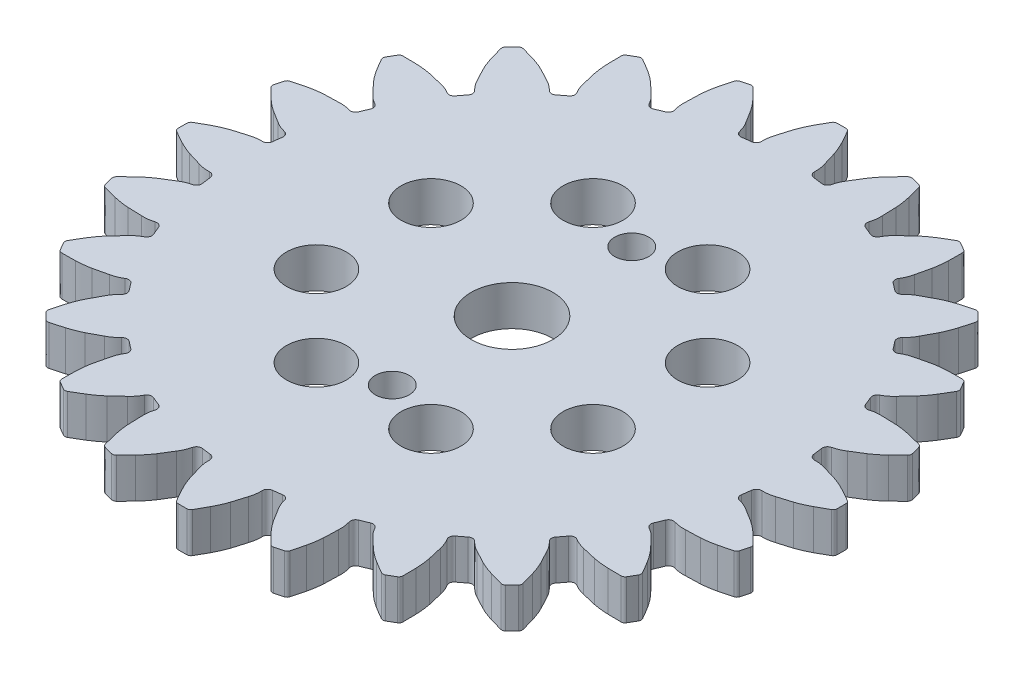
from build123d import *

# Parameters (mm, degrees)
BOSS_EXTRUDE1_DEPTH = 4
SKETCH2_R           = 4.1
CUT_EXTRUDE2_DEPTH  = 5
SKETCH3_R           = 1.7
CUT_EXTRUDE3_DEPTH  = 5
SKETCH4_R           = 3
CUT_EXTRUDE4_DEPTH  = 5


with BuildPart() as part:
    # Sketch1 → Boss-Extrude1 (new body)
    with BuildSketch(Plane(origin=(0, 0, 0), x_dir=(1, 0, 0), z_dir=(0, 1, 0))):
        with BuildLine():
            ThreePointArc((636.726842235, 307.914073759), (636.700055909, 308.139160781), (636.67140194, 308.364017679))
            ThreePointArc((636.67140194, 308.364017679), (636.640882301, 308.588628956), (636.608499097, 308.812979135))
            ThreePointArc((636.608499097, 308.812979135), (636.695878929, 309.191360962), (637.017496333, 309.409008123))
            ThreePointArc((637.017496333, 309.409008123), (637.592536167, 309.594733296), (638.123933391, 309.882451284))
            ThreePointArc((638.123933391, 309.882451284), (638.738760006, 310.263468262), (639.353529647, 310.644577163))
            ThreePointArc((639.353529647, 310.644577163), (639.964545893, 311.091711617), (640.534655463, 311.589953679))
            ThreePointArc((640.534655463, 311.589953679), (641.021585116, 312.059475229), (641.502718943, 312.534934179))
            ThreePointArc((641.502718943, 312.534934179), (641.605231633, 312.711177185), (641.607284789, 312.915055173))
            ThreePointArc((641.607284789, 312.915055173), (641.551805023, 313.130819634), (641.494870784, 313.346204869))
            ThreePointArc((641.494870784, 313.346204869), (641.436484664, 313.561201074), (641.376649319, 313.775798462))
            ThreePointArc((641.376649319, 313.775798462), (641.272932241, 313.9513354), (641.096032144, 314.052709976))
            ThreePointArc((641.096032144, 314.052709976), (640.441628552, 314.223902592), (639.785174328, 314.387055355))
            ThreePointArc((639.785174328, 314.387055355), (639.042323927, 314.533490853), (638.289601107, 314.615212526))
            ThreePointArc((638.289601107, 314.615212526), (637.566640531, 314.637877695), (636.843676574, 314.66043477))
            ThreePointArc((636.843676574, 314.66043477), (636.239614085, 314.643907245), (635.648752394, 314.517230045))
            ThreePointArc((635.648752394, 314.517230045), (635.261399971, 314.544909314), (634.996535903, 314.828907673))
            ThreePointArc((634.996535903, 314.828907673), (634.912405492, 315.039392229), (634.826530635, 315.249171121))
            ThreePointArc((634.826530635, 315.249171121), (634.738917252, 315.458229891), (634.649571379, 315.666554133))
            ThreePointArc((634.649571379, 315.666554133), (634.636041392, 316.054658476), (634.890368719, 316.3481302))
            ThreePointArc((634.890368719, 316.3481302), (635.397745334, 316.676358201), (635.836568741, 317.091808159))
            ThreePointArc((635.836568741, 317.091808159), (636.331831197, 317.618971136), (636.827014829, 318.146208157))
            ThreePointArc((636.827014829, 318.146208157), (637.301484289, 318.736249516), (637.723213312, 319.365069606))
            ThreePointArc((637.723213312, 319.365069606), (638.07203012, 319.944619264), (638.413711878, 320.528403941))
            ThreePointArc((638.413711878, 320.528403941), (638.467116486, 320.725173849), (638.416332176, 320.922636258))
            ThreePointArc((638.416332176, 320.922636258), (638.306898886, 321.116689504), (638.196158833, 321.31))
            ThreePointArc((638.196158833, 321.31), (638.084117059, 321.502558947), (637.970778664, 321.694357579))
            ThreePointArc((637.970778664, 321.694357579), (637.825163356, 321.837069287), (637.628053313, 321.889204493))
            ThreePointArc((637.628053313, 321.889204493), (636.951640073, 321.885191749), (636.275326942, 321.872882361))
            ThreePointArc((636.275326942, 321.872882361), (635.519888259, 321.822064359), (634.771662722, 321.706182432))
            ThreePointArc((634.771662722, 321.706182432), (634.067470253, 321.540959339), (633.363302494, 321.375630959))
            ThreePointArc((633.363302494, 321.375630959), (632.784100573, 321.203323719), (632.246158479, 320.928036682))
            ThreePointArc((632.246158479, 320.928036682), (631.864840847, 320.854518618), (631.53549762, 321.060288102))
            ThreePointArc((631.53549762, 321.060288102), (631.399756471, 321.241826018), (631.262512957, 321.422230819))
            ThreePointArc((631.262512957, 321.422230819), (631.123776535, 321.601490072), (630.983556768, 321.779591424))
            ThreePointArc((630.983556768, 321.779591424), (630.870039009, 322.150969614), (631.039744271, 322.500266287))
            ThreePointArc((631.039744271, 322.500266287), (631.444880789, 322.948628922), (631.76122529, 323.463498621))
            ThreePointArc((631.76122529, 323.463498621), (632.103172269, 324.100882311), (632.445023945, 324.738317121))
            ThreePointArc((632.445023945, 324.738317121), (632.75061231, 325.43105504), (632.995220649, 326.147600108))
            ThreePointArc((632.995220649, 326.147600108), (633.182153323, 326.797682524), (633.361097965, 327.450008967))
            ThreePointArc((633.361097965, 327.450008967), (633.361755056, 327.653896233), (633.261594147, 327.831486327))
            ThreePointArc((633.261594147, 327.831486327), (633.10566503, 327.990603949), (632.948665915, 328.148665915))
            ThreePointArc((632.948665915, 328.148665915), (632.790603949, 328.30566503), (632.631486327, 328.461594147))
            ThreePointArc((632.631486327, 328.461594147), (632.453896233, 328.561755056), (632.250008967, 328.561097965))
            ThreePointArc((632.250008967, 328.561097965), (631.597682524, 328.382153323), (630.947600108, 328.195220649))
            ThreePointArc((630.947600108, 328.195220649), (630.23105504, 327.95061231), (629.538317121, 327.645023945))
            ThreePointArc((629.538317121, 327.645023945), (628.900882311, 327.303172269), (628.263498621, 326.96122529))
            ThreePointArc((628.263498621, 326.96122529), (627.748628922, 326.644880789), (627.300266287, 326.239744271))
            ThreePointArc((627.300266287, 326.239744271), (626.950969614, 326.070039009), (626.579591424, 326.183556768))
            ThreePointArc((626.579591424, 326.183556768), (626.401490072, 326.323776535), (626.222230819, 326.462512957))
            ThreePointArc((626.222230819, 326.462512957), (626.041826018, 326.599756471), (625.860288102, 326.73549762))
            ThreePointArc((625.860288102, 326.73549762), (625.654518618, 327.064840847), (625.728036682, 327.446158479))
            ThreePointArc((625.728036682, 327.446158479), (626.003323719, 327.984100573), (626.175630959, 328.563302494))
            ThreePointArc((626.175630959, 328.563302494), (626.340959339, 329.267470253), (626.506182432, 329.971662722))
            ThreePointArc((626.506182432, 329.971662722), (626.622064359, 330.719888259), (626.672882361, 331.475326942))
            ThreePointArc((626.672882361, 331.475326942), (626.685191749, 332.151640073), (626.689204493, 332.828053313))
            ThreePointArc((626.689204493, 332.828053313), (626.637069287, 333.025163356), (626.494357579, 333.170778664))
            ThreePointArc((626.494357579, 333.170778664), (626.302558947, 333.284117059), (626.11, 333.396158833))
            ThreePointArc((626.11, 333.396158833), (625.916689504, 333.506898886), (625.722636258, 333.616332176))
            ThreePointArc((625.722636258, 333.616332176), (625.525173849, 333.667116486), (625.328403941, 333.613711878))
            ThreePointArc((625.328403941, 333.613711878), (624.744619264, 333.27203012), (624.165069606, 332.923213312))
            ThreePointArc((624.165069606, 332.923213312), (623.536249516, 332.501484289), (622.946208157, 332.027014829))
            ThreePointArc((622.946208157, 332.027014829), (622.418971136, 331.531831197), (621.891808159, 331.036568741))
            ThreePointArc((621.891808159, 331.036568741), (621.476358201, 330.597745334), (621.1481302, 330.090368719))
            ThreePointArc((621.1481302, 330.090368719), (620.854658476, 329.836041392), (620.466554133, 329.849571379))
            ThreePointArc((620.466554133, 329.849571379), (620.258229891, 329.938917252), (620.049171121, 330.026530635))
            ThreePointArc((620.049171121, 330.026530635), (619.839392229, 330.112405492), (619.628907673, 330.196535903))
            ThreePointArc((619.628907673, 330.196535903), (619.344909314, 330.461399971), (619.317230045, 330.848752394))
            ThreePointArc((619.317230045, 330.848752394), (619.443907245, 331.439614085), (619.46043477, 332.043676574))
            ThreePointArc((619.46043477, 332.043676574), (619.437877695, 332.766640531), (619.415212526, 333.489601107))
            ThreePointArc((619.415212526, 333.489601107), (619.333490853, 334.242323927), (619.187055355, 334.985174328))
            ThreePointArc((619.187055355, 334.985174328), (619.023902592, 335.641628552), (618.852709976, 336.296032144))
            ThreePointArc((618.852709976, 336.296032144), (618.7513354, 336.472932241), (618.575798462, 336.576649319))
            ThreePointArc((618.575798462, 336.576649319), (618.361201074, 336.636484664), (618.146204869, 336.694870784))
            ThreePointArc((618.146204869, 336.694870784), (617.930819634, 336.751805023), (617.715055173, 336.807284789))
            ThreePointArc((617.715055173, 336.807284789), (617.511177185, 336.805231633), (617.334934179, 336.702718943))
            ThreePointArc((617.334934179, 336.702718943), (616.859475229, 336.221585116), (616.389953679, 335.734655463))
            ThreePointArc((616.389953679, 335.734655463), (615.891711617, 335.164545893), (615.444577163, 334.553529647))
            ThreePointArc((615.444577163, 334.553529647), (615.063468262, 333.938760006), (614.682451284, 333.323933391))
            ThreePointArc((614.682451284, 333.323933391), (614.394733296, 332.792536167), (614.209008123, 332.217496333))
            ThreePointArc((614.209008123, 332.217496333), (613.991360962, 331.895878929), (613.612979135, 331.808499097))
            ThreePointArc((613.612979135, 331.808499097), (613.388628956, 331.840882301), (613.164017679, 331.87140194))
            ThreePointArc((613.164017679, 331.87140194), (612.939160781, 331.900055909), (612.714073759, 331.926842235))
            ThreePointArc((612.714073759, 331.926842235), (612.371200545, 332.109177094), (612.24421024, 332.476166881))
            ThreePointArc((612.24421024, 332.476166881), (612.21364476, 333.07968192), (612.073266247, 333.667439117))
            ThreePointArc((612.073266247, 333.667439117), (611.864360945, 334.359930475), (611.655352106, 335.052390589))
            ThreePointArc((611.655352106, 335.052390589), (611.381596031, 335.758313875), (611.047886369, 336.437951967))
            ThreePointArc((611.047886369, 336.437951967), (610.720390046, 337.029811013), (610.385658565, 337.617608434))
            ThreePointArc((610.385658565, 337.617608434), (610.24195313, 337.762243136), (610.045553512, 337.816993838))
            ThreePointArc((610.045553512, 337.816993838), (609.822781827, 337.819248451), (609.6, 337.82))
            ThreePointArc((609.6, 337.82), (609.377218173, 337.819248451), (609.154446488, 337.816993838))
            ThreePointArc((609.154446488, 337.816993838), (608.95804687, 337.762243136), (608.814341435, 337.617608434))
            ThreePointArc((608.814341435, 337.617608434), (608.479609954, 337.029811013), (608.152113631, 336.437951967))
            ThreePointArc((608.152113631, 336.437951967), (607.818403969, 335.758313875), (607.544647894, 335.052390589))
            ThreePointArc((607.544647894, 335.052390589), (607.335639055, 334.359930475), (607.126733753, 333.667439117))
            ThreePointArc((607.126733753, 333.667439117), (606.98635524, 333.07968192), (606.95578976, 332.476166881))
            ThreePointArc((606.95578976, 332.476166881), (606.828799455, 332.109177094), (606.485926241, 331.926842235))
            ThreePointArc((606.485926241, 331.926842235), (606.260839219, 331.900055909), (606.035982321, 331.87140194))
            ThreePointArc((606.035982321, 331.87140194), (605.811371044, 331.840882301), (605.587020865, 331.808499097))
            ThreePointArc((605.587020865, 331.808499097), (605.208639038, 331.895878929), (604.990991877, 332.217496333))
            ThreePointArc((604.990991877, 332.217496333), (604.805266704, 332.792536167), (604.517548716, 333.323933391))
            ThreePointArc((604.517548716, 333.323933391), (604.136531738, 333.938760006), (603.755422837, 334.553529647))
            ThreePointArc((603.755422837, 334.553529647), (603.308288383, 335.164545893), (602.810046321, 335.734655463))
            ThreePointArc((602.810046321, 335.734655463), (602.340524771, 336.221585116), (601.865065821, 336.702718943))
            ThreePointArc((601.865065821, 336.702718943), (601.688822815, 336.805231633), (601.484944827, 336.807284789))
            ThreePointArc((601.484944827, 336.807284789), (601.269180366, 336.751805023), (601.053795131, 336.694870784))
            ThreePointArc((601.053795131, 336.694870784), (600.838798926, 336.636484664), (600.624201538, 336.576649319))
            ThreePointArc((600.624201538, 336.576649319), (600.4486646, 336.472932241), (600.347290024, 336.296032144))
            ThreePointArc((600.347290024, 336.296032144), (600.176097408, 335.641628552), (600.012944645, 334.985174328))
            ThreePointArc((600.012944645, 334.985174328), (599.866509147, 334.242323927), (599.784787474, 333.489601107))
            ThreePointArc((599.784787474, 333.489601107), (599.762122305, 332.766640531), (599.73956523, 332.043676574))
            ThreePointArc((599.73956523, 332.043676574), (599.756092755, 331.439614085), (599.882769955, 330.848752394))
            ThreePointArc((599.882769955, 330.848752394), (599.855090686, 330.461399971), (599.571092327, 330.196535903))
            ThreePointArc((599.571092327, 330.196535903), (599.360607771, 330.112405492), (599.150828879, 330.026530635))
            ThreePointArc((599.150828879, 330.026530635), (598.941770109, 329.938917252), (598.733445867, 329.849571379))
            ThreePointArc((598.733445867, 329.849571379), (598.345341524, 329.836041392), (598.0518698, 330.090368719))
            ThreePointArc((598.0518698, 330.090368719), (597.723641799, 330.597745334), (597.308191841, 331.036568741))
            ThreePointArc((597.308191841, 331.036568741), (596.781028864, 331.531831197), (596.253791843, 332.027014829))
            ThreePointArc((596.253791843, 332.027014829), (595.663750484, 332.501484289), (595.034930394, 332.923213312))
            ThreePointArc((595.034930394, 332.923213312), (594.455380736, 333.27203012), (593.871596059, 333.613711878))
            ThreePointArc((593.871596059, 333.613711878), (593.674826151, 333.667116486), (593.477363742, 333.616332176))
            ThreePointArc((593.477363742, 333.616332176), (593.283310496, 333.506898886), (593.09, 333.396158833))
            ThreePointArc((593.09, 333.396158833), (592.897441053, 333.284117059), (592.705642421, 333.170778664))
            ThreePointArc((592.705642421, 333.170778664), (592.562930713, 333.025163356), (592.510795507, 332.828053313))
            ThreePointArc((592.510795507, 332.828053313), (592.514808251, 332.151640073), (592.527117639, 331.475326942))
            ThreePointArc((592.527117639, 331.475326942), (592.577935641, 330.719888259), (592.693817568, 329.971662722))
            ThreePointArc((592.693817568, 329.971662722), (592.859040661, 329.267470253), (593.024369041, 328.563302494))
            ThreePointArc((593.024369041, 328.563302494), (593.196676281, 327.984100573), (593.471963318, 327.446158479))
            ThreePointArc((593.471963318, 327.446158479), (593.545481382, 327.064840847), (593.339711898, 326.73549762))
            ThreePointArc((593.339711898, 326.73549762), (593.158173982, 326.599756471), (592.977769181, 326.462512957))
            ThreePointArc((592.977769181, 326.462512957), (592.798509928, 326.323776535), (592.620408576, 326.183556768))
            ThreePointArc((592.620408576, 326.183556768), (592.249030386, 326.070039009), (591.899733713, 326.239744271))
            ThreePointArc((591.899733713, 326.239744271), (591.451371078, 326.644880789), (590.936501379, 326.96122529))
            ThreePointArc((590.936501379, 326.96122529), (590.299117689, 327.303172269), (589.661682879, 327.645023945))
            ThreePointArc((589.661682879, 327.645023945), (588.96894496, 327.95061231), (588.252399892, 328.195220649))
            ThreePointArc((588.252399892, 328.195220649), (587.602317476, 328.382153323), (586.949991033, 328.561097965))
            ThreePointArc((586.949991033, 328.561097965), (586.746103767, 328.561755056), (586.568513673, 328.461594147))
            ThreePointArc((586.568513673, 328.461594147), (586.409396051, 328.30566503), (586.251334085, 328.148665915))
            ThreePointArc((586.251334085, 328.148665915), (586.09433497, 327.990603949), (585.938405853, 327.831486327))
            ThreePointArc((585.938405853, 327.831486327), (585.838244944, 327.653896233), (585.838902035, 327.450008967))
            ThreePointArc((585.838902035, 327.450008967), (586.017846677, 326.797682524), (586.204779351, 326.147600108))
            ThreePointArc((586.204779351, 326.147600108), (586.44938769, 325.43105504), (586.754976055, 324.73831712))
            ThreePointArc((586.754976055, 324.73831712), (587.096827731, 324.100882311), (587.43877471, 323.463498621))
            ThreePointArc((587.43877471, 323.463498621), (587.755119211, 322.948628922), (588.160255729, 322.500266287))
            ThreePointArc((588.160255729, 322.500266287), (588.329960991, 322.150969614), (588.216443232, 321.779591424))
            ThreePointArc((588.216443232, 321.779591424), (588.076223465, 321.601490072), (587.937487043, 321.422230819))
            ThreePointArc((587.937487043, 321.422230819), (587.800243529, 321.241826018), (587.66450238, 321.060288102))
            ThreePointArc((587.66450238, 321.060288102), (587.335159153, 320.854518618), (586.953841521, 320.928036682))
            ThreePointArc((586.953841521, 320.928036682), (586.415899427, 321.203323719), (585.836697506, 321.375630959))
            ThreePointArc((585.836697506, 321.375630959), (585.132529747, 321.540959339), (584.428337278, 321.706182432))
            ThreePointArc((584.428337278, 321.706182432), (583.680111741, 321.822064359), (582.924673058, 321.872882361))
            ThreePointArc((582.924673058, 321.872882361), (582.248359927, 321.885191749), (581.571946687, 321.889204493))
            ThreePointArc((581.571946687, 321.889204493), (581.374836644, 321.837069287), (581.229221336, 321.694357579))
            ThreePointArc((581.229221336, 321.694357579), (581.115882941, 321.502558947), (581.003841167, 321.31))
            ThreePointArc((581.003841167, 321.31), (580.893101114, 321.116689504), (580.783667824, 320.922636258))
            ThreePointArc((580.783667824, 320.922636258), (580.732883514, 320.725173849), (580.786288122, 320.528403941))
            ThreePointArc((580.786288122, 320.528403941), (581.12796988, 319.944619264), (581.476786688, 319.365069606))
            ThreePointArc((581.476786688, 319.365069606), (581.898515711, 318.736249516), (582.372985171, 318.146208157))
            ThreePointArc((582.372985171, 318.146208157), (582.868168803, 317.618971136), (583.363431259, 317.091808159))
            ThreePointArc((583.363431259, 317.091808159), (583.802254666, 316.676358201), (584.309631281, 316.3481302))
            ThreePointArc((584.309631281, 316.3481302), (584.563958608, 316.054658476), (584.550428621, 315.666554133))
            ThreePointArc((584.550428621, 315.666554133), (584.461082748, 315.458229891), (584.373469365, 315.249171121))
            ThreePointArc((584.373469365, 315.249171121), (584.287594508, 315.039392229), (584.203464097, 314.828907673))
            ThreePointArc((584.203464097, 314.828907673), (583.938600029, 314.544909314), (583.551247606, 314.517230045))
            ThreePointArc((583.551247606, 314.517230045), (582.960385915, 314.643907245), (582.356323426, 314.66043477))
            ThreePointArc((582.356323426, 314.66043477), (581.633359469, 314.637877695), (580.910398893, 314.615212526))
            ThreePointArc((580.910398893, 314.615212526), (580.157676073, 314.533490853), (579.414825672, 314.387055355))
            ThreePointArc((579.414825672, 314.387055355), (578.758371448, 314.223902592), (578.103967856, 314.052709976))
            ThreePointArc((578.103967856, 314.052709976), (577.927067759, 313.9513354), (577.823350681, 313.775798462))
            ThreePointArc((577.823350681, 313.775798462), (577.763515336, 313.561201074), (577.705129216, 313.346204869))
            ThreePointArc((577.705129216, 313.346204869), (577.648194977, 313.130819634), (577.592715211, 312.915055173))
            ThreePointArc((577.592715211, 312.915055173), (577.594768367, 312.711177185), (577.697281057, 312.534934179))
            ThreePointArc((577.697281057, 312.534934179), (578.178414884, 312.059475229), (578.665344537, 311.589953679))
            ThreePointArc((578.665344537, 311.589953679), (579.235454107, 311.091711617), (579.846470354, 310.644577163))
            ThreePointArc((579.846470354, 310.644577163), (580.461239994, 310.263468262), (581.076066609, 309.882451284))
            ThreePointArc((581.076066609, 309.882451284), (581.607463833, 309.594733296), (582.182503667, 309.409008123))
            ThreePointArc((582.182503667, 309.409008123), (582.504121071, 309.191360962), (582.591500903, 308.812979135))
            ThreePointArc((582.591500903, 308.812979135), (582.559117699, 308.588628956), (582.52859806, 308.364017679))
            ThreePointArc((582.52859806, 308.364017679), (582.499944091, 308.139160781), (582.473157765, 307.914073759))
            ThreePointArc((582.473157765, 307.914073759), (582.290822906, 307.571200545), (581.923833119, 307.44421024))
            ThreePointArc((581.923833119, 307.44421024), (581.32031808, 307.41364476), (580.732560883, 307.273266247))
            ThreePointArc((580.732560883, 307.273266247), (580.040069525, 307.064360945), (579.347609411, 306.855352106))
            ThreePointArc((579.347609411, 306.855352106), (578.641686125, 306.581596031), (577.962048033, 306.247886369))
            ThreePointArc((577.962048033, 306.247886369), (577.370188987, 305.920390046), (576.782391566, 305.585658565))
            ThreePointArc((576.782391566, 305.585658565), (576.637756864, 305.44195313), (576.583006162, 305.245553512))
            ThreePointArc((576.583006162, 305.245553512), (576.580751549, 305.022781827), (576.58, 304.8))
            ThreePointArc((576.58, 304.8), (576.580751549, 304.577218173), (576.583006162, 304.354446488))
            ThreePointArc((576.583006162, 304.354446488), (576.637756864, 304.15804687), (576.782391566, 304.014341435))
            ThreePointArc((576.782391566, 304.014341435), (577.370188987, 303.679609954), (577.962048033, 303.352113631))
            ThreePointArc((577.962048033, 303.352113631), (578.641686125, 303.018403969), (579.347609411, 302.744647894))
            ThreePointArc((579.347609411, 302.744647894), (580.040069526, 302.535639055), (580.732560883, 302.326733753))
            ThreePointArc((580.732560883, 302.326733753), (581.32031808, 302.18635524), (581.923833119, 302.15578976))
            ThreePointArc((581.923833119, 302.15578976), (582.290822906, 302.028799455), (582.473157765, 301.685926241))
            ThreePointArc((582.473157765, 301.685926241), (582.499944091, 301.460839219), (582.52859806, 301.235982321))
            ThreePointArc((582.52859806, 301.235982321), (582.559117699, 301.011371044), (582.591500903, 300.787020865))
            ThreePointArc((582.591500903, 300.787020865), (582.504121071, 300.408639038), (582.182503667, 300.190991877))
            ThreePointArc((582.182503667, 300.190991877), (581.607463833, 300.005266704), (581.076066609, 299.717548716))
            ThreePointArc((581.076066609, 299.717548716), (580.461239994, 299.336531738), (579.846470353, 298.955422837))
            ThreePointArc((579.846470353, 298.955422837), (579.235454107, 298.508288383), (578.665344537, 298.010046321))
            ThreePointArc((578.665344537, 298.010046321), (578.178414884, 297.540524771), (577.697281057, 297.065065821))
            ThreePointArc((577.697281057, 297.065065821), (577.594768367, 296.888822815), (577.592715211, 296.684944827))
            ThreePointArc((577.592715211, 296.684944827), (577.648194977, 296.469180366), (577.705129216, 296.253795131))
            ThreePointArc((577.705129216, 296.253795131), (577.763515336, 296.038798926), (577.823350681, 295.824201538))
            ThreePointArc((577.823350681, 295.824201538), (577.927067759, 295.6486646), (578.103967856, 295.547290024))
            ThreePointArc((578.103967856, 295.547290024), (578.758371448, 295.376097408), (579.414825672, 295.212944645))
            ThreePointArc((579.414825672, 295.212944645), (580.157676073, 295.066509147), (580.910398893, 294.984787474))
            ThreePointArc((580.910398893, 294.984787474), (581.633359469, 294.962122305), (582.356323426, 294.93956523))
            ThreePointArc((582.356323426, 294.93956523), (582.960385915, 294.956092755), (583.551247606, 295.082769955))
            ThreePointArc((583.551247606, 295.082769955), (583.938600029, 295.055090686), (584.203464097, 294.771092327))
            ThreePointArc((584.203464097, 294.771092327), (584.287594508, 294.560607771), (584.373469365, 294.350828879))
            ThreePointArc((584.373469365, 294.350828879), (584.461082748, 294.141770109), (584.550428621, 293.933445867))
            ThreePointArc((584.550428621, 293.933445867), (584.563958608, 293.545341524), (584.309631281, 293.2518698))
            ThreePointArc((584.309631281, 293.2518698), (583.802254666, 292.923641799), (583.363431259, 292.508191841))
            ThreePointArc((583.363431259, 292.508191841), (582.868168803, 291.981028864), (582.372985171, 291.453791843))
            ThreePointArc((582.372985171, 291.453791843), (581.898515711, 290.863750484), (581.476786688, 290.234930394))
            ThreePointArc((581.476786688, 290.234930394), (581.12796988, 289.655380736), (580.786288122, 289.071596059))
            ThreePointArc((580.786288122, 289.071596059), (580.732883514, 288.874826151), (580.783667824, 288.677363742))
            ThreePointArc((580.783667824, 288.677363742), (580.893101114, 288.483310496), (581.003841167, 288.29))
            ThreePointArc((581.003841167, 288.29), (581.115882941, 288.097441053), (581.229221336, 287.905642421))
            ThreePointArc((581.229221336, 287.905642421), (581.374836644, 287.762930713), (581.571946687, 287.710795507))
            ThreePointArc((581.571946687, 287.710795507), (582.248359927, 287.714808251), (582.924673058, 287.727117639))
            ThreePointArc((582.924673058, 287.727117639), (583.680111741, 287.777935641), (584.428337278, 287.893817568))
            ThreePointArc((584.428337278, 287.893817568), (585.132529747, 288.059040661), (585.836697506, 288.224369041))
            ThreePointArc((585.836697506, 288.224369041), (586.415899427, 288.396676281), (586.953841521, 288.671963318))
            ThreePointArc((586.953841521, 288.671963318), (587.335159153, 288.745481382), (587.66450238, 288.539711898))
            ThreePointArc((587.66450238, 288.539711898), (587.800243529, 288.358173982), (587.937487043, 288.177769181))
            ThreePointArc((587.937487043, 288.177769181), (588.076223465, 287.998509928), (588.216443232, 287.820408576))
            ThreePointArc((588.216443232, 287.820408576), (588.329960991, 287.449030386), (588.160255729, 287.099733713))
            ThreePointArc((588.160255729, 287.099733713), (587.755119211, 286.651371078), (587.43877471, 286.136501379))
            ThreePointArc((587.43877471, 286.136501379), (587.096827731, 285.499117689), (586.754976055, 284.861682879))
            ThreePointArc((586.754976055, 284.861682879), (586.44938769, 284.16894496), (586.204779351, 283.452399892))
            ThreePointArc((586.204779351, 283.452399892), (586.017846677, 282.802317476), (585.838902035, 282.149991033))
            ThreePointArc((585.838902035, 282.149991033), (585.838244944, 281.946103767), (585.938405853, 281.768513673))
            ThreePointArc((585.938405853, 281.768513673), (586.09433497, 281.609396051), (586.251334085, 281.451334085))
            ThreePointArc((586.251334085, 281.451334085), (586.409396051, 281.29433497), (586.568513673, 281.138405853))
            ThreePointArc((586.568513673, 281.138405853), (586.746103767, 281.038244944), (586.949991033, 281.038902035))
            ThreePointArc((586.949991033, 281.038902035), (587.602317476, 281.217846677), (588.252399892, 281.404779351))
            ThreePointArc((588.252399892, 281.404779351), (588.96894496, 281.64938769), (589.66168288, 281.954976055))
            ThreePointArc((589.66168288, 281.954976055), (590.299117689, 282.296827731), (590.936501379, 282.63877471))
            ThreePointArc((590.936501379, 282.63877471), (591.451371078, 282.955119211), (591.899733713, 283.360255729))
            ThreePointArc((591.899733713, 283.360255729), (592.249030386, 283.529960991), (592.620408576, 283.416443232))
            ThreePointArc((592.620408576, 283.416443232), (592.798509928, 283.276223465), (592.977769181, 283.137487043))
            ThreePointArc((592.977769181, 283.137487043), (593.158173982, 283.000243529), (593.339711898, 282.86450238))
            ThreePointArc((593.339711898, 282.86450238), (593.545481382, 282.535159153), (593.471963318, 282.153841521))
            ThreePointArc((593.471963318, 282.153841521), (593.196676281, 281.615899427), (593.024369041, 281.036697506))
            ThreePointArc((593.024369041, 281.036697506), (592.859040661, 280.332529747), (592.693817568, 279.628337278))
            ThreePointArc((592.693817568, 279.628337278), (592.577935641, 278.880111741), (592.527117639, 278.124673058))
            ThreePointArc((592.527117639, 278.124673058), (592.514808251, 277.448359927), (592.510795507, 276.771946687))
            ThreePointArc((592.510795507, 276.771946687), (592.562930713, 276.574836644), (592.705642421, 276.429221336))
            ThreePointArc((592.705642421, 276.429221336), (592.897441053, 276.315882941), (593.09, 276.203841167))
            ThreePointArc((593.09, 276.203841167), (593.283310496, 276.093101114), (593.477363742, 275.983667824))
            ThreePointArc((593.477363742, 275.983667824), (593.674826151, 275.932883514), (593.871596059, 275.986288122))
            ThreePointArc((593.871596059, 275.986288122), (594.455380736, 276.32796988), (595.034930394, 276.676786688))
            ThreePointArc((595.034930394, 276.676786688), (595.663750484, 277.098515711), (596.253791843, 277.572985171))
            ThreePointArc((596.253791843, 277.572985171), (596.781028864, 278.068168803), (597.308191841, 278.563431259))
            ThreePointArc((597.308191841, 278.563431259), (597.723641799, 279.002254666), (598.0518698, 279.509631281))
            ThreePointArc((598.0518698, 279.509631281), (598.345341524, 279.763958608), (598.733445867, 279.750428621))
            ThreePointArc((598.733445867, 279.750428621), (598.941770109, 279.661082748), (599.150828879, 279.573469365))
            ThreePointArc((599.150828879, 279.573469365), (599.360607771, 279.487594508), (599.571092327, 279.403464097))
            ThreePointArc((599.571092327, 279.403464097), (599.855090686, 279.138600029), (599.882769955, 278.751247606))
            ThreePointArc((599.882769955, 278.751247606), (599.756092755, 278.160385915), (599.73956523, 277.556323426))
            ThreePointArc((599.73956523, 277.556323426), (599.762122305, 276.833359469), (599.784787474, 276.110398892))
            ThreePointArc((599.784787474, 276.110398892), (599.866509147, 275.357676073), (600.012944645, 274.614825672))
            ThreePointArc((600.012944645, 274.614825672), (600.176097408, 273.958371448), (600.347290024, 273.303967856))
            ThreePointArc((600.347290024, 273.303967856), (600.4486646, 273.127067759), (600.624201538, 273.023350681))
            ThreePointArc((600.624201538, 273.023350681), (600.838798926, 272.963515336), (601.053795131, 272.905129216))
            ThreePointArc((601.053795131, 272.905129216), (601.269180366, 272.848194977), (601.484944827, 272.792715211))
            ThreePointArc((601.484944827, 272.792715211), (601.688822815, 272.794768367), (601.865065821, 272.897281057))
            ThreePointArc((601.865065821, 272.897281057), (602.340524771, 273.378414884), (602.810046321, 273.865344537))
            ThreePointArc((602.810046321, 273.865344537), (603.308288383, 274.435454107), (603.755422837, 275.046470354))
            ThreePointArc((603.755422837, 275.046470354), (604.136531738, 275.661239994), (604.517548716, 276.276066609))
            ThreePointArc((604.517548716, 276.276066609), (604.805266704, 276.807463833), (604.990991877, 277.382503667))
            ThreePointArc((604.990991877, 277.382503667), (605.208639038, 277.704121071), (605.587020865, 277.791500903))
            ThreePointArc((605.587020865, 277.791500903), (605.811371044, 277.759117699), (606.035982321, 277.72859806))
            ThreePointArc((606.035982321, 277.72859806), (606.260839219, 277.699944091), (606.485926241, 277.673157765))
            ThreePointArc((606.485926241, 277.673157765), (606.828799455, 277.490822906), (606.95578976, 277.123833119))
            ThreePointArc((606.95578976, 277.123833119), (606.98635524, 276.52031808), (607.126733753, 275.932560883))
            ThreePointArc((607.126733753, 275.932560883), (607.335639055, 275.240069525), (607.544647894, 274.547609411))
            ThreePointArc((607.544647894, 274.547609411), (607.818403969, 273.841686125), (608.152113631, 273.162048033))
            ThreePointArc((608.152113631, 273.162048033), (608.479609954, 272.570188987), (608.814341435, 271.982391566))
            ThreePointArc((608.814341435, 271.982391566), (608.95804687, 271.837756864), (609.154446488, 271.783006162))
            ThreePointArc((609.154446488, 271.783006162), (609.377218173, 271.780751549), (609.6, 271.78))
            ThreePointArc((609.6, 271.78), (609.822781827, 271.780751549), (610.045553512, 271.783006162))
            ThreePointArc((610.045553512, 271.783006162), (610.24195313, 271.837756864), (610.385658565, 271.982391566))
            ThreePointArc((610.385658565, 271.982391566), (610.720390046, 272.570188987), (611.047886369, 273.162048033))
            ThreePointArc((611.047886369, 273.162048033), (611.381596031, 273.841686125), (611.655352106, 274.547609411))
            ThreePointArc((611.655352106, 274.547609411), (611.864360945, 275.240069525), (612.073266247, 275.932560882))
            ThreePointArc((612.073266247, 275.932560882), (612.21364476, 276.52031808), (612.24421024, 277.123833119))
            ThreePointArc((612.24421024, 277.123833119), (612.371200545, 277.490822906), (612.714073759, 277.673157765))
            ThreePointArc((612.714073759, 277.673157765), (612.939160781, 277.699944091), (613.164017679, 277.72859806))
            ThreePointArc((613.164017679, 277.72859806), (613.388628956, 277.759117699), (613.612979135, 277.791500903))
            ThreePointArc((613.612979135, 277.791500903), (613.991360962, 277.704121071), (614.209008123, 277.382503667))
            ThreePointArc((614.209008123, 277.382503667), (614.394733296, 276.807463833), (614.682451284, 276.276066609))
            ThreePointArc((614.682451284, 276.276066609), (615.063468262, 275.661239994), (615.444577163, 275.046470353))
            ThreePointArc((615.444577163, 275.046470353), (615.891711617, 274.435454107), (616.389953679, 273.865344537))
            ThreePointArc((616.389953679, 273.865344537), (616.859475229, 273.378414884), (617.334934179, 272.897281057))
            ThreePointArc((617.334934179, 272.897281057), (617.511177185, 272.794768367), (617.715055173, 272.792715211))
            ThreePointArc((617.715055173, 272.792715211), (617.930819634, 272.848194977), (618.146204869, 272.905129216))
            ThreePointArc((618.146204869, 272.905129216), (618.361201074, 272.963515336), (618.575798462, 273.023350681))
            ThreePointArc((618.575798462, 273.023350681), (618.7513354, 273.127067759), (618.852709976, 273.303967856))
            ThreePointArc((618.852709976, 273.303967856), (619.023902592, 273.958371448), (619.187055355, 274.614825672))
            ThreePointArc((619.187055355, 274.614825672), (619.333490853, 275.357676073), (619.415212526, 276.110398893))
            ThreePointArc((619.415212526, 276.110398893), (619.437877695, 276.833359469), (619.46043477, 277.556323426))
            ThreePointArc((619.46043477, 277.556323426), (619.443907245, 278.160385915), (619.317230045, 278.751247606))
            ThreePointArc((619.317230045, 278.751247606), (619.344909314, 279.138600029), (619.628907673, 279.403464097))
            ThreePointArc((619.628907673, 279.403464097), (619.839392229, 279.487594508), (620.049171121, 279.573469365))
            ThreePointArc((620.049171121, 279.573469365), (620.258229891, 279.661082748), (620.466554133, 279.750428621))
            ThreePointArc((620.466554133, 279.750428621), (620.854658476, 279.763958608), (621.1481302, 279.509631281))
            ThreePointArc((621.1481302, 279.509631281), (621.476358201, 279.002254666), (621.891808159, 278.563431259))
            ThreePointArc((621.891808159, 278.563431259), (622.418971136, 278.068168803), (622.946208157, 277.572985171))
            ThreePointArc((622.946208157, 277.572985171), (623.536249516, 277.098515711), (624.165069606, 276.676786688))
            ThreePointArc((624.165069606, 276.676786688), (624.744619264, 276.32796988), (625.328403941, 275.986288122))
            ThreePointArc((625.328403941, 275.986288122), (625.525173849, 275.932883514), (625.722636258, 275.983667824))
            ThreePointArc((625.722636258, 275.983667824), (625.916689504, 276.093101114), (626.11, 276.203841167))
            ThreePointArc((626.11, 276.203841167), (626.302558947, 276.315882941), (626.494357579, 276.429221336))
            ThreePointArc((626.494357579, 276.429221336), (626.637069287, 276.574836644), (626.689204493, 276.771946687))
            ThreePointArc((626.689204493, 276.771946687), (626.685191749, 277.448359927), (626.672882361, 278.124673058))
            ThreePointArc((626.672882361, 278.124673058), (626.622064359, 278.880111741), (626.506182432, 279.628337278))
            ThreePointArc((626.506182432, 279.628337278), (626.340959339, 280.332529747), (626.175630959, 281.036697506))
            ThreePointArc((626.175630959, 281.036697506), (626.003323719, 281.615899427), (625.728036682, 282.153841521))
            ThreePointArc((625.728036682, 282.153841521), (625.654518618, 282.535159153), (625.860288102, 282.86450238))
            ThreePointArc((625.860288102, 282.86450238), (626.041826018, 283.000243529), (626.222230819, 283.137487043))
            ThreePointArc((626.222230819, 283.137487043), (626.401490072, 283.276223465), (626.579591424, 283.416443232))
            ThreePointArc((626.579591424, 283.416443232), (626.950969614, 283.529960991), (627.300266287, 283.360255729))
            ThreePointArc((627.300266287, 283.360255729), (627.748628922, 282.955119211), (628.263498621, 282.63877471))
            ThreePointArc((628.263498621, 282.63877471), (628.900882311, 282.296827731), (629.538317121, 281.954976055))
            ThreePointArc((629.538317121, 281.954976055), (630.23105504, 281.64938769), (630.947600108, 281.404779351))
            ThreePointArc((630.947600108, 281.404779351), (631.597682524, 281.217846677), (632.250008967, 281.038902035))
            ThreePointArc((632.250008967, 281.038902035), (632.453896233, 281.038244944), (632.631486327, 281.138405853))
            ThreePointArc((632.631486327, 281.138405853), (632.790603949, 281.29433497), (632.948665915, 281.451334085))
            ThreePointArc((632.948665915, 281.451334085), (633.10566503, 281.609396051), (633.261594147, 281.768513673))
            ThreePointArc((633.261594147, 281.768513673), (633.361755056, 281.946103767), (633.361097965, 282.149991033))
            ThreePointArc((633.361097965, 282.149991033), (633.182153323, 282.802317476), (632.995220649, 283.452399892))
            ThreePointArc((632.995220649, 283.452399892), (632.75061231, 284.16894496), (632.445023945, 284.861682879))
            ThreePointArc((632.445023945, 284.861682879), (632.103172269, 285.499117689), (631.76122529, 286.136501379))
            ThreePointArc((631.76122529, 286.136501379), (631.444880789, 286.651371078), (631.039744271, 287.099733713))
            ThreePointArc((631.039744271, 287.099733713), (630.870039009, 287.449030386), (630.983556768, 287.820408576))
            ThreePointArc((630.983556768, 287.820408576), (631.123776535, 287.998509928), (631.262512957, 288.177769181))
            ThreePointArc((631.262512957, 288.177769181), (631.399756471, 288.358173982), (631.53549762, 288.539711898))
            ThreePointArc((631.53549762, 288.539711898), (631.864840847, 288.745481382), (632.246158479, 288.671963318))
            ThreePointArc((632.246158479, 288.671963318), (632.784100573, 288.396676281), (633.363302494, 288.224369041))
            ThreePointArc((633.363302494, 288.224369041), (634.067470253, 288.059040661), (634.771662722, 287.893817568))
            ThreePointArc((634.771662722, 287.893817568), (635.519888259, 287.777935641), (636.275326942, 287.727117639))
            ThreePointArc((636.275326942, 287.727117639), (636.951640073, 287.714808251), (637.628053313, 287.710795507))
            ThreePointArc((637.628053313, 287.710795507), (637.825163356, 287.762930713), (637.970778664, 287.905642421))
            ThreePointArc((637.970778664, 287.905642421), (638.084117059, 288.097441053), (638.196158833, 288.29))
            ThreePointArc((638.196158833, 288.29), (638.306898886, 288.483310496), (638.416332176, 288.677363742))
            ThreePointArc((638.416332176, 288.677363742), (638.467116486, 288.874826151), (638.413711878, 289.071596059))
            ThreePointArc((638.413711878, 289.071596059), (638.07203012, 289.655380736), (637.723213312, 290.234930394))
            ThreePointArc((637.723213312, 290.234930394), (637.301484289, 290.863750484), (636.827014829, 291.453791843))
            ThreePointArc((636.827014829, 291.453791843), (636.331831197, 291.981028864), (635.836568741, 292.508191841))
            ThreePointArc((635.836568741, 292.508191841), (635.397745334, 292.923641799), (634.890368719, 293.2518698))
            ThreePointArc((634.890368719, 293.2518698), (634.636041392, 293.545341524), (634.649571379, 293.933445867))
            ThreePointArc((634.649571379, 293.933445867), (634.738917252, 294.141770109), (634.826530635, 294.350828879))
            ThreePointArc((634.826530635, 294.350828879), (634.912405492, 294.560607771), (634.996535903, 294.771092327))
            ThreePointArc((634.996535903, 294.771092327), (635.261399971, 295.055090686), (635.648752394, 295.082769955))
            ThreePointArc((635.648752394, 295.082769955), (636.239614085, 294.956092755), (636.843676574, 294.93956523))
            ThreePointArc((636.843676574, 294.93956523), (637.566640531, 294.962122305), (638.289601108, 294.984787474))
            ThreePointArc((638.289601108, 294.984787474), (639.042323927, 295.066509147), (639.785174328, 295.212944645))
            ThreePointArc((639.785174328, 295.212944645), (640.441628552, 295.376097408), (641.096032144, 295.547290024))
            ThreePointArc((641.096032144, 295.547290024), (641.272932241, 295.6486646), (641.376649319, 295.824201538))
            ThreePointArc((641.376649319, 295.824201538), (641.436484664, 296.038798926), (641.494870784, 296.253795131))
            ThreePointArc((641.494870784, 296.253795131), (641.551805023, 296.469180366), (641.607284789, 296.684944827))
            ThreePointArc((641.607284789, 296.684944827), (641.605231633, 296.888822815), (641.502718943, 297.065065821))
            ThreePointArc((641.502718943, 297.065065821), (641.021585116, 297.540524771), (640.534655463, 298.010046321))
            ThreePointArc((640.534655463, 298.010046321), (639.964545893, 298.508288383), (639.353529647, 298.955422837))
            ThreePointArc((639.353529647, 298.955422837), (638.738760006, 299.336531738), (638.123933391, 299.717548716))
            ThreePointArc((638.123933391, 299.717548716), (637.592536167, 300.005266704), (637.017496333, 300.190991877))
            ThreePointArc((637.017496333, 300.190991877), (636.695878929, 300.408639038), (636.608499097, 300.787020865))
            ThreePointArc((636.608499097, 300.787020865), (636.640882301, 301.011371044), (636.67140194, 301.235982321))
            ThreePointArc((636.67140194, 301.235982321), (636.700055909, 301.460839219), (636.726842235, 301.685926241))
            ThreePointArc((636.726842235, 301.685926241), (636.909177094, 302.028799455), (637.276166881, 302.15578976))
            ThreePointArc((637.276166881, 302.15578976), (637.87968192, 302.18635524), (638.467439117, 302.326733753))
            ThreePointArc((638.467439117, 302.326733753), (639.159930475, 302.535639055), (639.852390589, 302.744647894))
            ThreePointArc((639.852390589, 302.744647894), (640.558313875, 303.018403969), (641.237951967, 303.352113631))
            ThreePointArc((641.237951967, 303.352113631), (641.829811013, 303.679609954), (642.417608434, 304.014341435))
            ThreePointArc((642.417608434, 304.014341435), (642.562243136, 304.15804687), (642.616993838, 304.354446488))
            ThreePointArc((642.616993838, 304.354446488), (642.619248451, 304.577218173), (642.62, 304.8))
            ThreePointArc((642.62, 304.8), (642.619248451, 305.022781827), (642.616993838, 305.245553512))
            ThreePointArc((642.616993838, 305.245553512), (642.562243136, 305.44195313), (642.417608434, 305.585658565))
            ThreePointArc((642.417608434, 305.585658565), (641.829811013, 305.920390046), (641.237951967, 306.247886369))
            ThreePointArc((641.237951967, 306.247886369), (640.558313875, 306.581596031), (639.852390589, 306.855352106))
            ThreePointArc((639.852390589, 306.855352106), (639.159930475, 307.064360945), (638.467439117, 307.273266247))
            ThreePointArc((638.467439117, 307.273266247), (637.87968192, 307.41364476), (637.276166881, 307.44421024))
            ThreePointArc((637.276166881, 307.44421024), (636.909177094, 307.571200545), (636.726842235, 307.914073759))
        make_face()
    extrude(amount=BOSS_EXTRUDE1_DEPTH)

    # Sketch2 → Cut-Extrude2 (cut, through all)
    with BuildSketch(Plane(origin=(0, 0, 0), x_dir=(1, 0, 0), z_dir=(0, 1, 0))):
        with Locations((609.6, 304.8)):
            Circle(SKETCH2_R)
    extrude(amount=CUT_EXTRUDE2_DEPTH, mode=Mode.SUBTRACT)

    # Sketch3 → Cut-Extrude3 (cut, through all)
    with BuildSketch(Plane(origin=(0, 0, 0), x_dir=(1, 0, 0), z_dir=(0, 1, 0))):
        with Locations((609.6, 316.8)):
            Circle(SKETCH3_R)
        with Locations((609.6, 292.8)):
            Circle(SKETCH3_R)
    extrude(amount=CUT_EXTRUDE3_DEPTH, mode=Mode.SUBTRACT)

    # Sketch4 → Cut-Extrude4 (cut, through all)
    with BuildSketch(Plane(origin=(0, 0, 0), x_dir=(1, 0, 0), z_dir=(0, 1, 0))):
        with Locations((615.340251485, 318.658192988)):
            Circle(SKETCH4_R)
        with Locations((623.458192988, 310.540251485)):
            Circle(SKETCH4_R)
        with Locations((623.458192988, 299.059748515)):
            Circle(SKETCH4_R)
        with Locations((615.340251485, 290.941807012)):
            Circle(SKETCH4_R)
        with Locations((603.859748515, 290.941807012)):
            Circle(SKETCH4_R)
        with Locations((595.741807012, 299.059748515)):
            Circle(SKETCH4_R)
        with Locations((595.741807012, 310.540251485)):
            Circle(SKETCH4_R)
        with Locations((603.859748515, 318.658192988)):
            Circle(SKETCH4_R)
    extrude(amount=CUT_EXTRUDE4_DEPTH, mode=Mode.SUBTRACT)


solid = part.part
